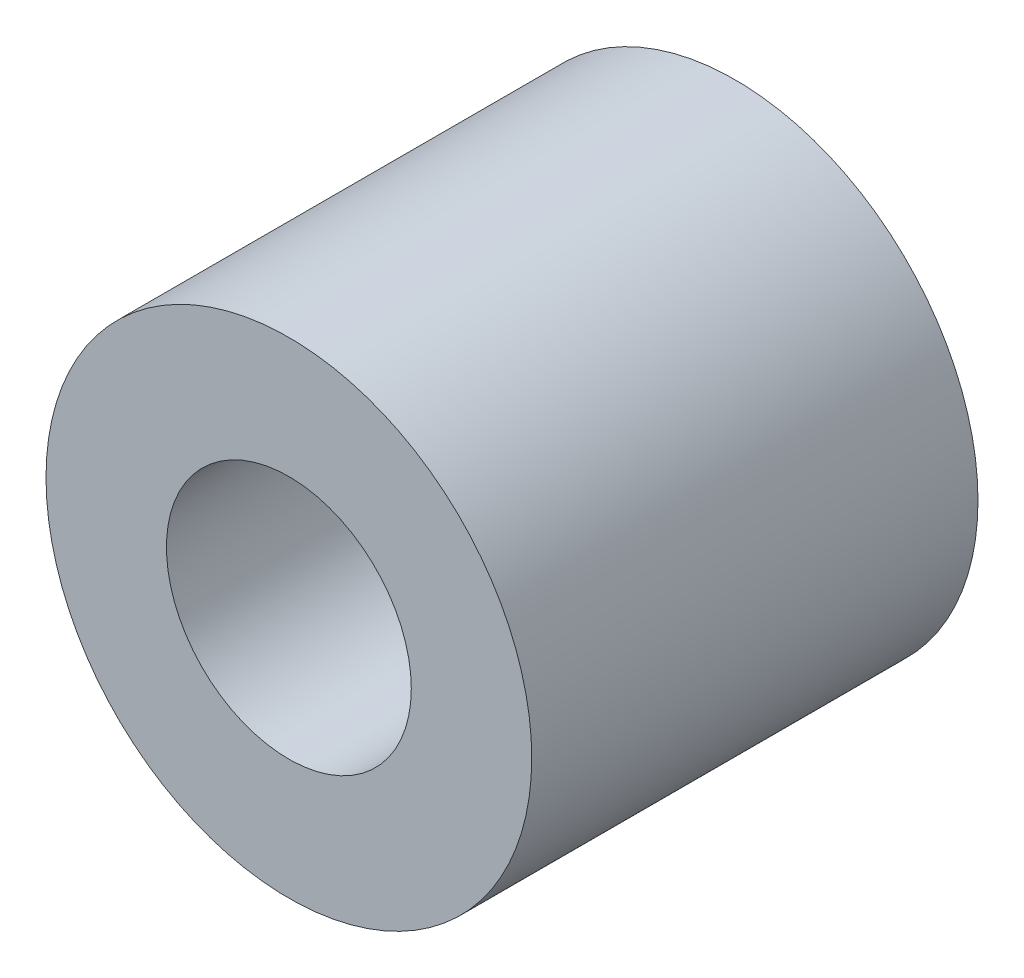
from build123d import *

# Parameters (mm, degrees)
SKETCH1_R           = 3.1242
SKETCH1_R_2         = 1.5748
BOSS_EXTRUDE1_DEPTH = 5.7404


with BuildPart() as part:
    # Sketch1 → Boss-Extrude1 (new body)
    with BuildSketch(Plane.XY):
        Circle(SKETCH1_R)
        Circle(SKETCH1_R_2, mode=Mode.SUBTRACT)
    extrude(amount=BOSS_EXTRUDE1_DEPTH)


solid = part.part
